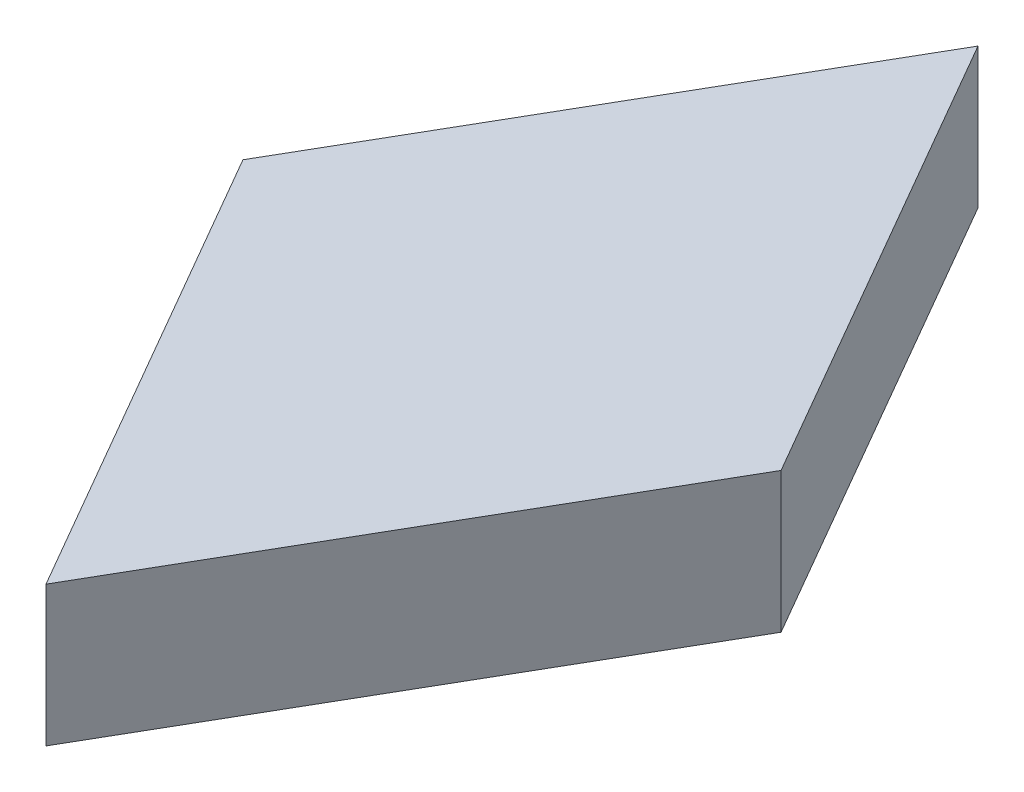
from build123d import *

# Parameters (mm, degrees)
BOSS_EXTRUDE1_DEPTH = 2
SKETCH2_R           = 1.5
CUT_EXTRUDE1_DEPTH  = 1


with BuildPart() as part:
    # Sketch1 → Boss-Extrude1 (new body)
    with BuildSketch(Plane(origin=(0, 0, 0), x_dir=(1, 0, 0), z_dir=(0, 1, 0))):
        Polygon((0, 6.651075101), (-3.84, 0), (0, -6.651075101), (3.84, 0), align=None)
    extrude(amount=BOSS_EXTRUDE1_DEPTH)

    # Sketch2 → Cut-Extrude1 (cut)
    with BuildSketch(Plane(origin=(0, 0, 0), x_dir=(-1, 0, 0), z_dir=(0, -1, 0))):
        Circle(SKETCH2_R)
    extrude(amount=-CUT_EXTRUDE1_DEPTH, mode=Mode.SUBTRACT)


solid = part.part
